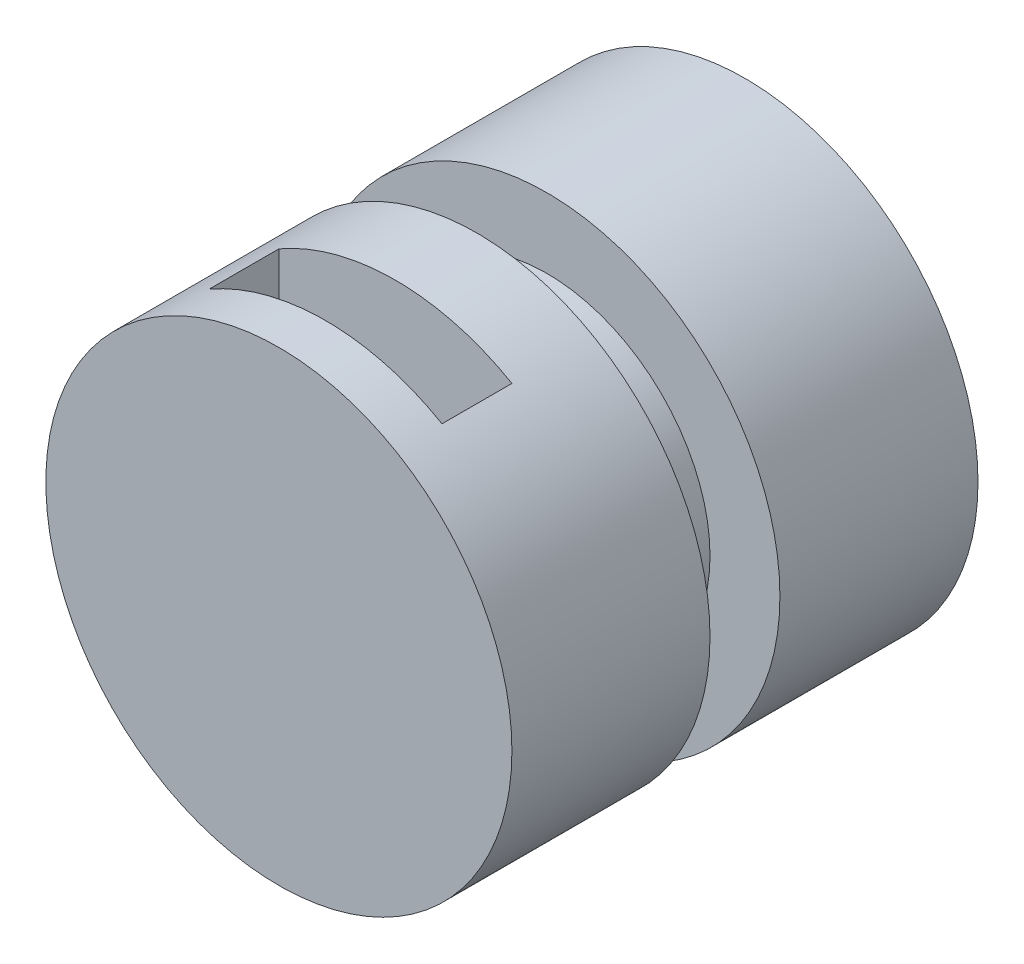
from build123d import *

# Parameters (mm, degrees)
SKETCH1_W               = 1000
SKETCH1_H               = 2000
SKETCH4_W               = 1000
SKETCH4_H               = 300
CUT_EXTRUDE1_DEPTH      = 1001
CUT_EXTRUDE1_DEPTH_BACK = 1001
SKETCH5_W               = 300
SKETCH5_H               = 300


with BuildPart() as part:
    # Sketch1 → Revolve1 (revolve)
    with BuildSketch(Plane(origin=(0, 0, 0), x_dir=(1, 0, 0), z_dir=(0, 1, 0))):
        with Locations((-500, -1000)):
            Rectangle(SKETCH1_W, SKETCH1_H)
    revolve(axis=Axis((0, 0, 2000), (0, 0, -1)))

    # Sketch4 → Cut-Extrude1 (cut, two sides)
    with BuildSketch(Plane(origin=(0, 0, 0), x_dir=(1, 0, 0), z_dir=(0, 1, 0))) as cut_extrude1_sk:
        with Locations((0, -1650)):
            Rectangle(SKETCH4_W, SKETCH4_H)
    extrude(amount=CUT_EXTRUDE1_DEPTH, mode=Mode.SUBTRACT)
    extrude(cut_extrude1_sk.sketch, amount=-CUT_EXTRUDE1_DEPTH_BACK, mode=Mode.SUBTRACT)

    # Sketch5 → Cut-Revolve1 (revolve, cut)
    with BuildSketch(Plane(origin=(0, 0, 0), x_dir=(1, 0, 0), z_dir=(0, 1, 0))):
        with Locations((-850, -1000)):
            Rectangle(SKETCH5_W, SKETCH5_H)
    revolve(axis=Axis((0, 0, 2000), (0, 0, -1)), mode=Mode.SUBTRACT)


solid = part.part
